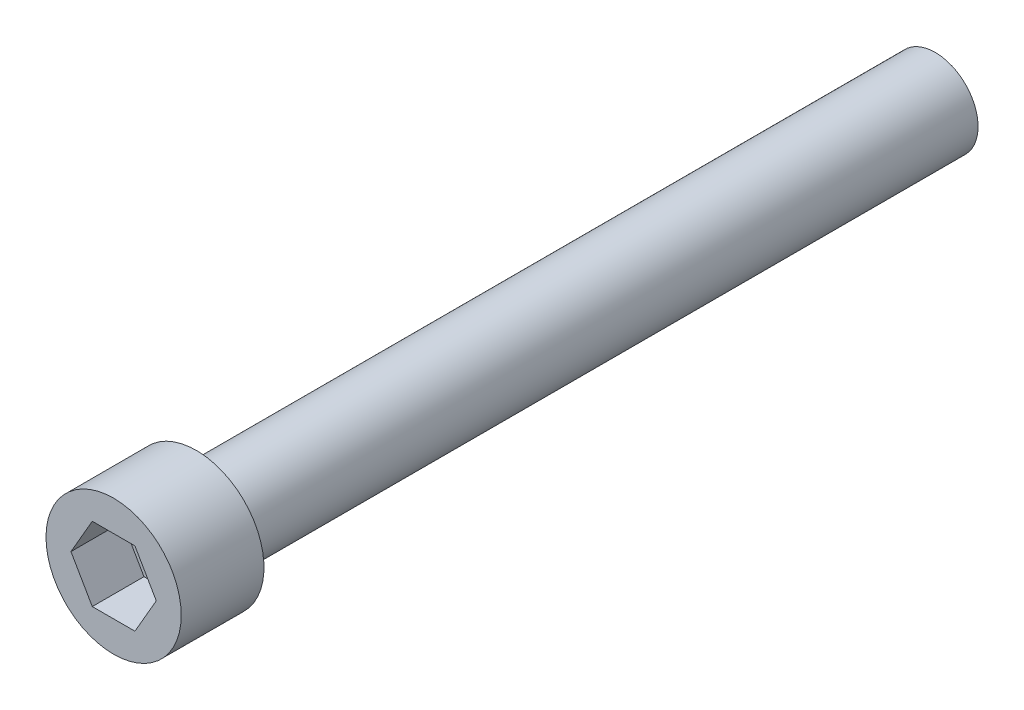
from build123d import *

# Parameters (mm, degrees)
SKETCH1_R         = 2.3241
EXTRUDE1_DEPTH    = 28.2448
SKETCH3_OUTSIDE_W = 12.448
SKETCH3_OUTSIDE_H = 12.448
SKETCH3_OUTSIDE_R = 1.4732
EXTRUDE2_DEPTH    = 25.4
EXTRUDE3_DEPTH    = 1.778


with BuildPart() as part:
    # Sketch1 → Extrude1 (new body)
    with BuildSketch(Plane.XY):
        Circle(SKETCH1_R)
    extrude(amount=EXTRUDE1_DEPTH)

    # Sketch3 outside → Extrude2 (cut)
    with BuildSketch(Plane(origin=(0, 0, 0), x_dir=(-1, 0, 0), z_dir=(0, 0, -1))):
        Rectangle(SKETCH3_OUTSIDE_W, SKETCH3_OUTSIDE_H)
        Circle(SKETCH3_OUTSIDE_R, mode=Mode.SUBTRACT)
    extrude(amount=-EXTRUDE2_DEPTH, mode=Mode.SUBTRACT)

    # Sketch4 → Extrude3 (cut)
    with BuildSketch(Plane.XY.offset(28.2448)):
        Polygon((1.466469684, 0), (0.733234842, 1.27), (-0.733234842, 1.27), (-1.466469684, 0), (-0.733234842, -1.27), (0.733234842, -1.27), align=None)
    extrude(amount=-EXTRUDE3_DEPTH, mode=Mode.SUBTRACT)


solid = part.part
